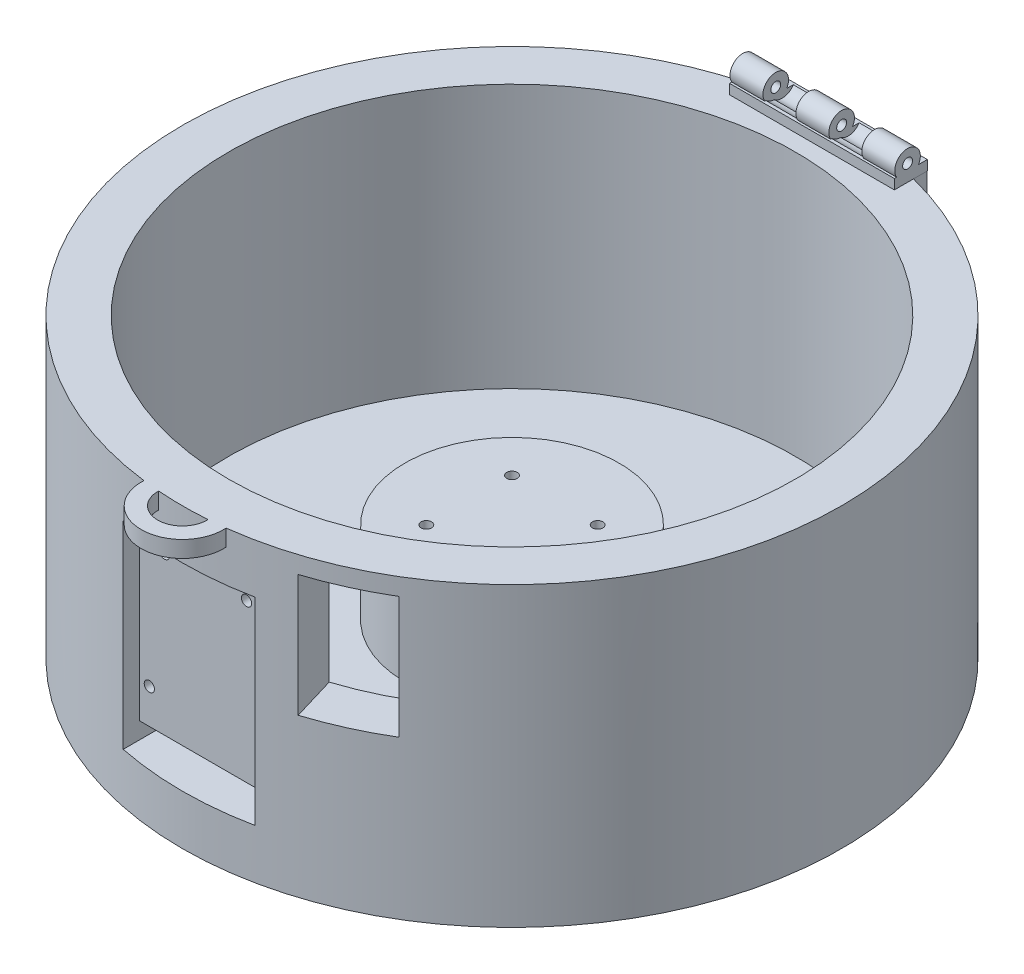
from build123d import *

# Parameters (mm, degrees)
SKETCH1_R               = 100
BOSS_EXTRUDE3_DEPTH     = 90
SKETCH4_W               = 40
SKETCH4_H               = 60
CUT_EXTRUDE2_DEPTH      = 26
CUT_EXTRUDE2_DEPTH_BACK = 12
SKETCH12_R              = 100
BOSS_EXTRUDE4_DEPTH     = 0.1
SKETCH13_R              = 86
CUT_EXTRUDE8_DEPTH      = 80
SKETCH18_R              = 32.5
BOSS_EXTRUDE5_DEPTH     = 25
SKETCH16_R              = 1.6
CUT_EXTRUDE11_DEPTH     = 91.1
SKETCH17_R              = 3
CUT_EXTRUDE12_DEPTH     = 30
SKETCH19_R              = 30
CUT_EXTRUDE13_DEPTH     = 25
SKETCH20_W              = 40
SKETCH20_H              = 5
CUT_EXTRUDE14_DEPTH     = 25
SKETCH21_R              = 1.55
CUT_EXTRUDE15_DEPTH     = 25
SKETCH23_W              = 50
SKETCH23_H              = 15
BOSS_EXTRUDE6_DEPTH     = 3
SKETCH24_W              = 50
SKETCH24_H              = 6
BOSS_EXTRUDE7_DEPTH     = 4
SKETCH25_R              = 1.5
CUT_EXTRUDE17_DEPTH     = 126
BOSS_EXTRUDE8_DEPTH     = 50
SKETCH29_W              = 10
SKETCH29_H              = 11
CUT_EXTRUDE20_DEPTH     = 10
CUT_EXTRUDE21_START     = -10
CUT_EXTRUDE21_DEPTH     = 10
LPATTERN1_COUNT         = 2
LPATTERN1_PITCH         = 20
SKETCH31_R              = 3.881248585
SKETCH31_R_2            = 1.5
BOSS_EXTRUDE9_DEPTH     = 10
SKETCH33_R              = 3.881248585
SKETCH33_R_2            = 1.5
BOSS_EXTRUDE11_DEPTH    = 10
SKETCH34_R              = 3.881248585
SKETCH34_R_2            = 1.5
BOSS_EXTRUDE12_DEPTH    = 10
SKETCH36_R              = 3.881248585
SKETCH36_R_2            = 1.5
CUT_EXTRUDE22_DEPTH     = 10
SKETCH37_R              = 3.881248585
SKETCH37_R_2            = 1.5
CUT_EXTRUDE23_DEPTH     = 10
SKETCH38_W              = 50
SKETCH38_H              = 5
CUT_EXTRUDE24_DEPTH     = 3
SKETCH39_W              = 49.970802014
SKETCH39_H              = 1.005140431
BOSS_EXTRUDE13_DEPTH    = 10
BOSS_EXTRUDE14_REACH    = 203.024
SKETCH40_W              = 49.970802014
SKETCH40_H              = 10
SKETCH41_R              = 12.5
SKETCH41_R_2            = 7.5
BOSS_EXTRUDE15_DEPTH    = 5
CUT_EXTRUDE25_DEPTH     = 37


with BuildPart() as part:
    # Sketch1 → Boss-Extrude3 (new body)
    with BuildSketch(Plane(origin=(0, 0, 0), x_dir=(1, 0, 0), z_dir=(0, 1, 0))):
        Circle(SKETCH1_R)
    extrude(amount=BOSS_EXTRUDE3_DEPTH)

    # Sketch4 → Cut-Extrude2 (cut, two sides)
    with BuildSketch(Plane.XY.offset(105)) as cut_extrude2_sk:
        with Locations((0, 45)):
            Rectangle(SKETCH4_W, SKETCH4_H)
    extrude(amount=CUT_EXTRUDE2_DEPTH, mode=Mode.SUBTRACT)
    extrude(cut_extrude2_sk.sketch, amount=-CUT_EXTRUDE2_DEPTH_BACK, mode=Mode.SUBTRACT)

    # Sketch12 → Boss-Extrude4 (add)
    with BuildSketch(Plane.XZ):
        Circle(SKETCH12_R)
    extrude(amount=BOSS_EXTRUDE4_DEPTH)

    # Sketch13 → Cut-Extrude8 (cut)
    with BuildSketch(Plane(origin=(0, 90, 0), x_dir=(1, 0, 0), z_dir=(0, 1, 0))):
        Circle(SKETCH13_R)
    extrude(amount=-CUT_EXTRUDE8_DEPTH, mode=Mode.SUBTRACT)

    # Sketch18 → Boss-Extrude5 (add)
    with BuildSketch(Plane(origin=(0, 10, 0), x_dir=(1, 0, 0), z_dir=(0, 1, 0))):
        Circle(SKETCH18_R)
    extrude(amount=BOSS_EXTRUDE5_DEPTH)

    # Sketch16 → Cut-Extrude11 (cut, through all)
    with BuildSketch(Plane.XZ.offset(0.1)):
        with Locations((-13, 13)):
            Circle(SKETCH16_R)
        with Locations((13, 13)):
            Circle(SKETCH16_R)
        with Locations((13, -13)):
            Circle(SKETCH16_R)
        with Locations((-13, -13)):
            Circle(SKETCH16_R)
    extrude(amount=-CUT_EXTRUDE11_DEPTH, mode=Mode.SUBTRACT)

    # Sketch17 → Cut-Extrude12 (cut)
    with BuildSketch(Plane.XZ.offset(0.1)):
        with Locations((-13, 13)):
            Circle(SKETCH17_R)
        with Locations((13, 13)):
            Circle(SKETCH17_R)
        with Locations((-13, -13)):
            Circle(SKETCH17_R)
        with Locations((13, -13)):
            Circle(SKETCH17_R)
    extrude(amount=-CUT_EXTRUDE12_DEPTH, mode=Mode.SUBTRACT)

    # Sketch19 → Cut-Extrude13 (cut)
    with BuildSketch(Plane.XZ.offset(0.1)):
        Circle(SKETCH19_R)
    extrude(amount=-CUT_EXTRUDE13_DEPTH, mode=Mode.SUBTRACT)

    # Sketch20 → Cut-Extrude14 (cut)
    with BuildSketch(Plane.XY.offset(93)):
        with Locations((0, 17.5)):
            Rectangle(SKETCH20_W, SKETCH20_H)
    extrude(amount=-CUT_EXTRUDE14_DEPTH, mode=Mode.SUBTRACT)

    # Sketch21 → Cut-Extrude15 (cut)
    with BuildSketch(Plane.XY.offset(93)):
        with Locations((12.45, 67.8)):
            Circle(SKETCH21_R)
        with Locations((-12.45, 67.8)):
            Circle(SKETCH21_R)
        with Locations((-17.05, 30.54)):
            Circle(SKETCH21_R)
        with Locations((17.05, 30.54)):
            Circle(SKETCH21_R)
    extrude(amount=-CUT_EXTRUDE15_DEPTH, mode=Mode.SUBTRACT)

    # Sketch23 → Boss-Extrude6 (add)
    with BuildSketch(Plane(origin=(0, 90, 0), x_dir=(1, 0, 0), z_dir=(0, 1, 0))):
        with Locations((0, 93.523512725)):
            Rectangle(SKETCH23_W, SKETCH23_H)
    extrude(amount=BOSS_EXTRUDE6_DEPTH)

    # Sketch24 → Boss-Extrude7 (add)
    with BuildSketch(Plane(origin=(0, 93, 0), x_dir=(1, 0, 0), z_dir=(0, 1, 0))):
        with Locations((0, 95.023512725)):
            Rectangle(SKETCH24_W, SKETCH24_H)
    extrude(amount=BOSS_EXTRUDE7_DEPTH)

    # Sketch25 → Cut-Extrude17 (cut, through all)
    with BuildSketch(Plane(origin=(25, 0, 0), x_dir=(0, 0, -1), z_dir=(1, 0, 0))):
        with Locations((95.023512725, 95)):
            Circle(SKETCH25_R)
    extrude(amount=-CUT_EXTRUDE17_DEPTH, mode=Mode.SUBTRACT)

    # Sketch27 → Boss-Extrude8 (add)
    with BuildSketch(Plane(origin=(25, 0, 0), x_dir=(0, 0, -1), z_dir=(1, 0, 0))):
        with BuildLine():
            Line((92.023512725, 97), (98.023512725, 97))
            ThreePointArc((98.023512725, 97), (95.023512725, 98.854101966), (92.023512725, 97))
        make_face()
    extrude(amount=-BOSS_EXTRUDE8_DEPTH)

    # Sketch29 → Cut-Extrude20 (cut, through all)
    with BuildSketch(Plane.XY.offset(-92.023512725)):
        with Locations((-10, 98.5)):
            Rectangle(SKETCH29_W, SKETCH29_H)
        with Locations((10, 98.5)):
            Rectangle(SKETCH29_W, SKETCH29_H)
    extrude(amount=-CUT_EXTRUDE20_DEPTH, mode=Mode.SUBTRACT)

    # Sketch30 → Cut-Extrude21 (cut)
    with BuildSketch(Plane(origin=(25, 0, 0), x_dir=(0, 0, -1), z_dir=(1, 0, 0)).offset(CUT_EXTRUDE21_START)):
        with BuildLine():
            Line((92.023512725, 93), (98.023512725, 93))
            ThreePointArc((98.023512725, 93), (95.023512725, 91.890227771), (92.023512725, 93))
        make_face()
    cut_extrude21 = extrude(amount=-CUT_EXTRUDE21_DEPTH, mode=Mode.SUBTRACT)

    # LPattern1: Cut-Extrude21 ×2
    with Locations(*[(-i * LPATTERN1_PITCH, 0, 0) for i in range(1, LPATTERN1_COUNT)]):
        add(cut_extrude21, mode=Mode.SUBTRACT)

    # Sketch31 → Boss-Extrude9 (add)
    with BuildSketch(Plane(origin=(25, 0, 0), x_dir=(0, 0, -1), z_dir=(1, 0, 0))):
        with Locations((95.023512725, 95)):
            Circle(SKETCH31_R)
        with Locations((95.023512725, 95)):
            Circle(SKETCH31_R_2, mode=Mode.SUBTRACT)
    extrude(amount=-BOSS_EXTRUDE9_DEPTH)

    # Sketch33 → Boss-Extrude11 (add)
    with BuildSketch(Plane(origin=(5, 0, 0), x_dir=(0, 0, -1), z_dir=(1, 0, 0))):
        with Locations((95.023512725, 95)):
            Circle(SKETCH33_R)
        with Locations((95.023512725, 95)):
            Circle(SKETCH33_R_2, mode=Mode.SUBTRACT)
    extrude(amount=-BOSS_EXTRUDE11_DEPTH)

    # Sketch34 → Boss-Extrude12 (add)
    with BuildSketch(Plane(origin=(-15, 0, 0), x_dir=(0, 0, -1), z_dir=(1, 0, 0))):
        with Locations((95.023512725, 95)):
            Circle(SKETCH34_R)
        with Locations((95.023512725, 95)):
            Circle(SKETCH34_R_2, mode=Mode.SUBTRACT)
    extrude(amount=-BOSS_EXTRUDE12_DEPTH)

    # Sketch36 → Cut-Extrude22 (cut)
    with BuildSketch(Plane.ZY.offset(-15)):
        with Locations((-97.029162036, 95.048788547)):
            Circle(SKETCH36_R)
        with Locations((-97.029162036, 95.048788547)):
            Circle(SKETCH36_R_2, mode=Mode.SUBTRACT)
    extrude(amount=CUT_EXTRUDE22_DEPTH, mode=Mode.SUBTRACT)

    # Sketch37 → Cut-Extrude23 (cut)
    with BuildSketch(Plane.ZY.offset(5)):
        with Locations((-97.009847138, 94.987072973)):
            Circle(SKETCH37_R)
        with Locations((-97.009847138, 94.987072973)):
            Circle(SKETCH37_R_2, mode=Mode.SUBTRACT)
    extrude(amount=CUT_EXTRUDE23_DEPTH, mode=Mode.SUBTRACT)

    # Sketch38 → Cut-Extrude24 (cut)
    with BuildSketch(Plane(origin=(0, 93, 0), x_dir=(1, 0, 0), z_dir=(0, 1, 0))):
        with Locations((0, 88.523512725)):
            Rectangle(SKETCH38_W, SKETCH38_H)
    extrude(amount=-CUT_EXTRUDE24_DEPTH, mode=Mode.SUBTRACT)

    # Sketch39 → Boss-Extrude13 (add)
    with BuildSketch(Plane(origin=(0, 90, 0), x_dir=(-1, 0, 0), z_dir=(0, -1, 0))):
        with Locations((0.014598993, 100.52094251)):
            Rectangle(SKETCH39_W, SKETCH39_H)
    extrude(amount=BOSS_EXTRUDE13_DEPTH)

    # Sketch40 → Boss-Extrude14 (add, up to next)
    with BuildSketch(Plane(origin=(0, 0, -101.023512725), x_dir=(-1, 0, 0), z_dir=(0, 0, -1)), mode=Mode.PRIVATE) as boss_extrude14_sk1:
        with Locations((0.014598993, 85)):
            Rectangle(SKETCH40_W, SKETCH40_H)
    boss_extrude14_tool1 = extrude(boss_extrude14_sk1.sketch, amount=-BOSS_EXTRUDE14_REACH, mode=Mode.PRIVATE) - part.part
    add(boss_extrude14_tool1.solids().sort_by_distance((-0.014599, 85, -101.023513))[0])

    # Sketch41 → Boss-Extrude15 (add)
    with BuildSketch(Plane(origin=(0, 90, 0), x_dir=(1, 0, 0), z_dir=(0, 1, 0))):
        with Locations((0, -100)):
            Circle(SKETCH41_R)
        with Locations((0, -100)):
            Circle(SKETCH41_R_2, mode=Mode.SUBTRACT)
    extrude(amount=-BOSS_EXTRUDE15_DEPTH)

    # Sketch42 → Cut-Extrude25 (cut)
    with BuildSketch(Plane(origin=(22.204096953, 47.794122581, -296.404157649), x_dir=(1, 0, 0), z_dir=(0, 1, 0))):
        Polygon((-8.101888311, -337.261049447), (12.404969277, -405.762485644), (37.058002756, -394.3841625), (-1.388931435, -334.195344764), align=None)
    extrude(amount=CUT_EXTRUDE25_DEPTH, mode=Mode.SUBTRACT)


solid = part.part
